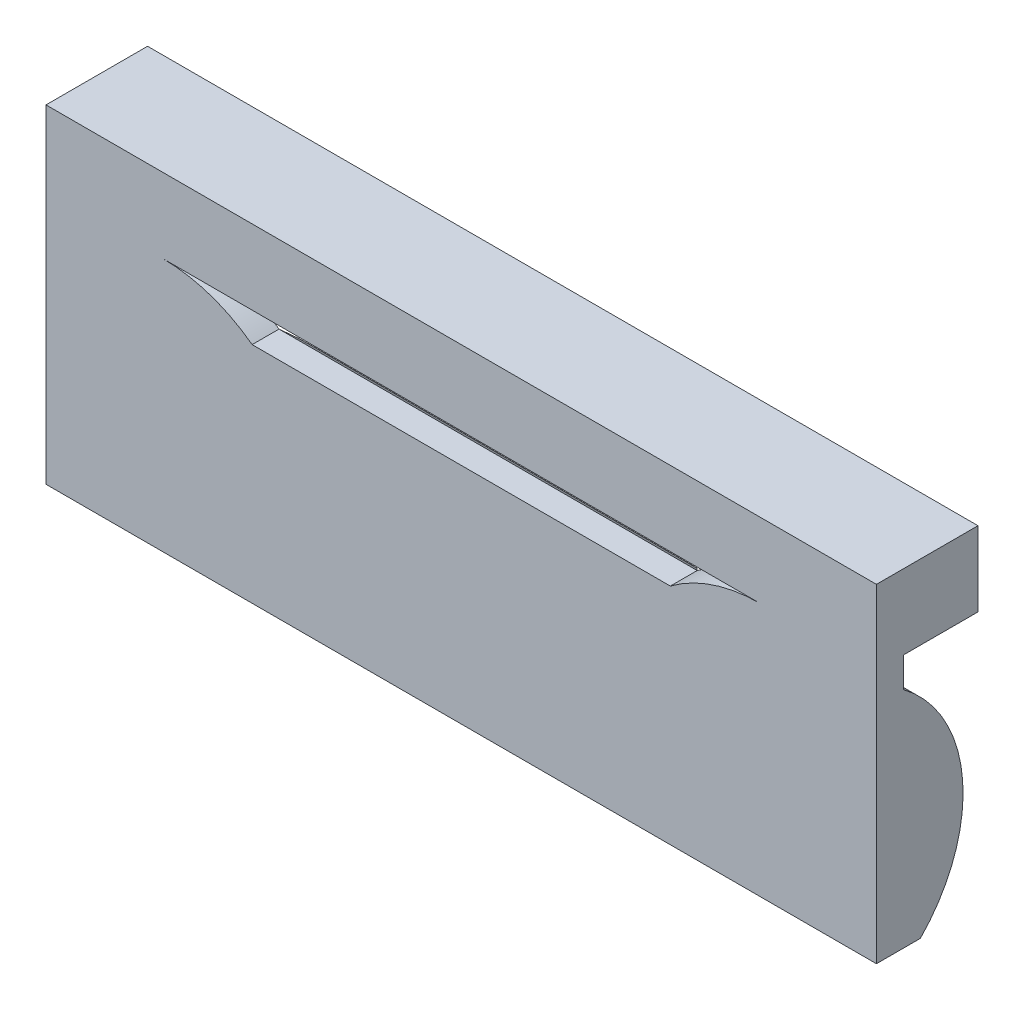
from build123d import *

# Parameters (mm, degrees)
SKETCH1_W               = 13
SKETCH1_H               = 4.5
BOSS_EXTRUDE1_DEPTH     = 0.225
BOSS_EXTRUDE2_DEPTH     = 1.25
BOSS_EXTRUDE3_DEPTH     = 2
SKETCH4_W               = 7
SKETCH4_H               = 0.5
CUT_EXTRUDE1_DEPTH      = 3.45
CUT_EXTRUDE2_DEPTH      = 7.95
CUT_EXTRUDE2_DEPTH_BACK = 7.95


with BuildPart() as part:
    # Sketch1 → Boss-Extrude1 (new body, symmetric)
    with BuildSketch(Plane.XY):
        Polygon((6.95, 2.25), (6.95, 2.75), (6.5, 2.75), (-6.5, 2.75), (-6.95, 2.75), (-6.95, 2.25), (-6.95, -2.25), (-6.95, -2.75), (-6.5, -2.75), (6.5, -2.75), (6.95, -2.75), (6.95, -2.25), align=None)
        Rectangle(SKETCH1_W, SKETCH1_H, mode=Mode.SUBTRACT)
        with BuildLine():
            Line((6.5, 1.875), (6.5, 2.25))
            Line((6.5, 2.25), (-6.5, 2.25))
            Line((-6.5, 2.25), (-6.5, 1.875))
            Line((-6.5, 1.875), (-6.5, 1))
            Line((-6.5, 1), (-6.5, -2.25))
            Line((-6.5, -2.25), (-2.834936491, -2.25))
            ThreePointArc((-2.834936491, -2.25), (-2.834936491, 0.25), (-5, 1.5))
            Line((-5, 1.5), (5, 1.5))
            ThreePointArc((5, 1.5), (2.834936491, 0.25), (2.834936491, -2.25))
            Line((2.834936491, -2.25), (6.5, -2.25))
            Line((6.5, -2.25), (6.5, 1))
            Line((6.5, 1), (6.5, 1.875))
        make_face()
        with BuildLine():
            Line((-2.834936491, -2.25), (2.834936491, -2.25))
            ThreePointArc((2.834936491, -2.25), (2.834936491, 0.25), (5, 1.5))
            Line((5, 1.5), (-5, 1.5))
            ThreePointArc((-5, 1.5), (-2.834936491, 0.25), (-2.834936491, -2.25))
        make_face()
    extrude(amount=BOSS_EXTRUDE1_DEPTH, both=True)

    # Sketch2 → Boss-Extrude2 (add)
    with BuildSketch(Plane(origin=(0, 0, -0.225), x_dir=(-1, 0, 0), z_dir=(0, 0, -1))):
        Polygon((-6.95, 2.25), (-6.95, -2.25), (-6.95, -2.75), (-6.5, -2.75), (6.5, -2.75), (6.95, -2.75), (6.95, -2.25), (6.95, 2.25), (6.95, 2.75), (6.5, 2.75), (-6.5, 2.75), (-6.95, 2.75), align=None)
        Polygon((-6.5, 1), (-6.5, 1.875), (-6.5, 2.25), (6.5, 2.25), (6.5, 1.875), (6.5, 1), (6.5, -2.25), (2.834936491, -2.25), (-2.834936491, -2.25), (-6.5, -2.25), align=None, mode=Mode.SUBTRACT)
    extrude(amount=BOSS_EXTRUDE2_DEPTH)

    # Sketch3 → Boss-Extrude3 (add)
    with BuildSketch(Plane(origin=(0, 0, -0.225), x_dir=(-1, 0, 0), z_dir=(0, 0, -1))):
        with BuildLine():
            ThreePointArc((-5, 1.5), (-2.834936491, 0.25), (-2.834936491, -2.25))
            Line((-2.834936491, -2.25), (2.834936491, -2.25))
            ThreePointArc((2.834936491, -2.25), (2.834936491, 0.25), (5, 1.5))
            Line((5, 1.5), (-5, 1.5))
        make_face()
    extrude(amount=BOSS_EXTRUDE3_DEPTH)

    # Sketch4 → Cut-Extrude1 (cut, through all)
    with BuildSketch(Plane(origin=(0, 0, -2.225), x_dir=(-1, 0, 0), z_dir=(0, 0, -1))):
        with Locations((0, 1.25)):
            Rectangle(SKETCH4_W, SKETCH4_H)
        with BuildLine():
            Line((3.5, 1.5), (3.5, 1))
            ThreePointArc((3.5, 1), (4.209430585, 1.371708245), (5, 1.5))
            Line((5, 1.5), (3.5, 1.5))
        make_face()
        with BuildLine():
            ThreePointArc((-5, 1.5), (-4.209430585, 1.371708245), (-3.5, 1))
            Line((-3.5, 1), (-3.5, 1.5))
            Line((-3.5, 1.5), (-5, 1.5))
        make_face()
    extrude(amount=-CUT_EXTRUDE1_DEPTH, mode=Mode.SUBTRACT)

    # Sketch5 → Cut-Extrude2 (cut, two sides)
    with BuildSketch(Plane(origin=(0, 0, 0), x_dir=(0, 0, -1), z_dir=(1, 0, 0))) as cut_extrude2_sk:
        with BuildLine():
            Line((3.725, 1.5), (0.225, 1.5))
            Line((0.225, 1.5), (0.225, 1))
            ThreePointArc((0.225, 1), (1.096708245, -1.790569415), (-1.275, -3.5))
            Line((-1.275, -3.5), (3.725, -3.5))
            Line((3.725, -3.5), (3.725, 1.5))
        make_face()
    extrude(amount=CUT_EXTRUDE2_DEPTH, mode=Mode.SUBTRACT)
    extrude(cut_extrude2_sk.sketch, amount=-CUT_EXTRUDE2_DEPTH_BACK, mode=Mode.SUBTRACT)


solid = part.part
